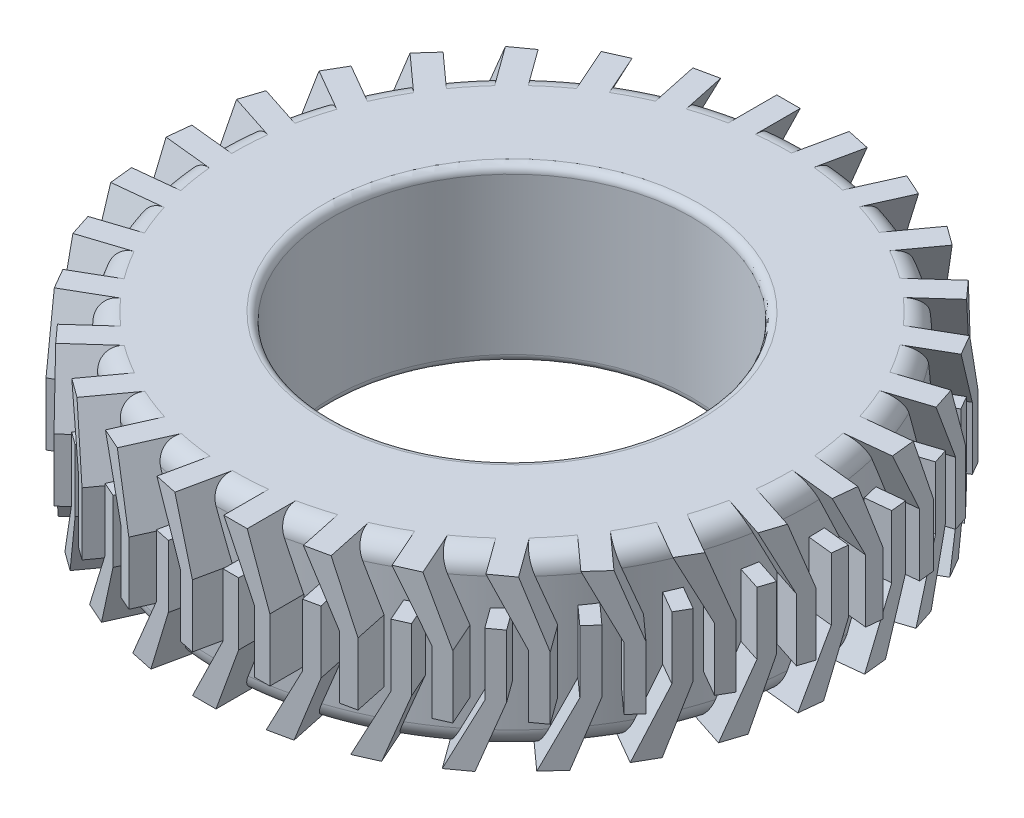
from build123d import *

# Parameters (mm, degrees)
BOSS_EXTRUDE2_START = -32.168659
BOSS_EXTRUDE2_DEPTH = 62.168659
CIRPATTERN1_COUNT   = 30


with BuildPart() as part:
    # Sketch1 → Revolve1 (revolve)
    with BuildSketch(Plane.XY):
        with BuildLine():
            Line((355, 220), (240, 220))
            ThreePointArc((240, 220), (232.928932188, 217.071067812), (230, 210))
            Line((230, 210), (230, 10))
            ThreePointArc((230, 10), (232.928932188, 2.928932188), (240, 0))
            Line((240, 0), (355, 0))
            ThreePointArc((355, 0), (372.67766953, 7.32233047), (380, 25))
            Line((380, 25), (380, 195))
            ThreePointArc((380, 195), (372.67766953, 212.67766953), (355, 220))
        make_face()
    revolve(axis=Axis((0, 0, 0), (0, 1, 0)))

    # Sketch2 → Boss-Extrude2 (add)
    with BuildSketch(Plane.XY.offset(380).offset(BOSS_EXTRUDE2_START)):
        Polygon((80, 140), (40.981392915, 220), (70.981392915, 220), (100, 140), (100, 60), (80, 60), align=None)
        Polygon((40, 160), (60, 160), (60, 80), (30.981392915, 0), (0.981392915, 0), (40, 80), align=None)
    boss_extrude2 = extrude(amount=BOSS_EXTRUDE2_DEPTH)

    # CirPattern1: Boss-Extrude2 ×30 about axis
    cirpattern1_axis = Axis((0, 0, 0), (0, 1, 0))
    for i in range(1, CIRPATTERN1_COUNT):
        add(boss_extrude2.rotate(cirpattern1_axis, i * 360 / CIRPATTERN1_COUNT))


solid = part.part
